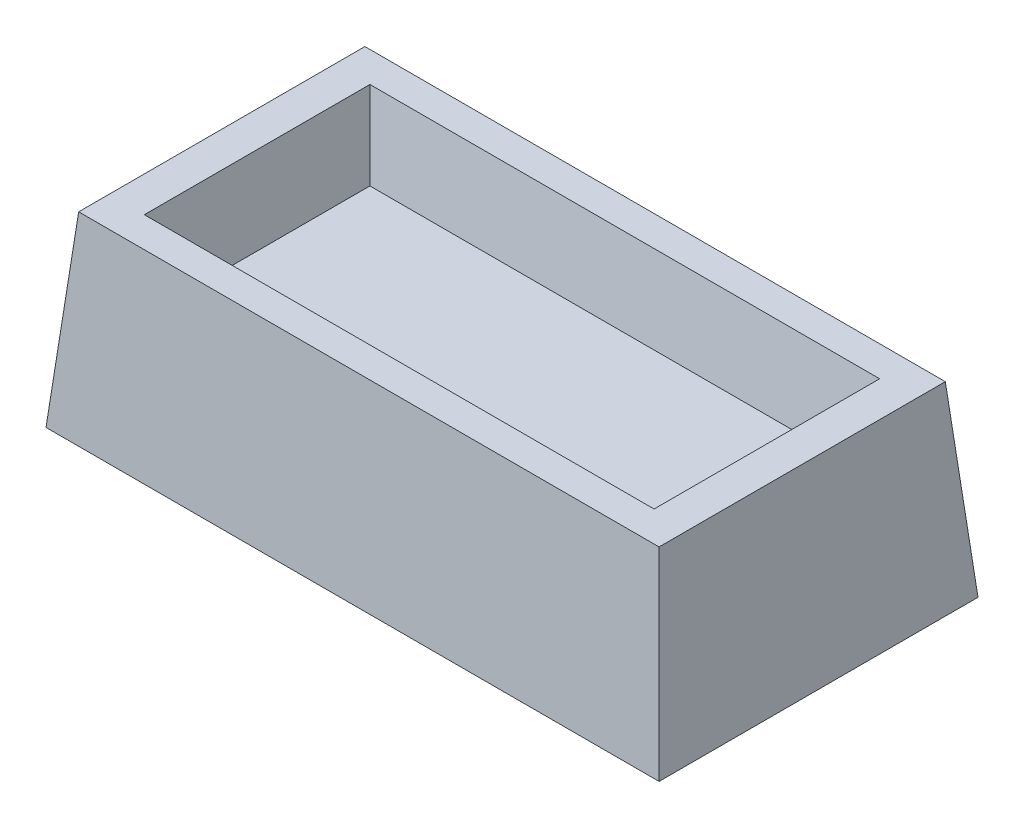
from build123d import *

# Parameters (mm, degrees)
SKETCH1_W           = 164.136897748
SKETCH1_H           = 85.377660522
BOSS_EXTRUDE1_DEPTH = 50
BOSS_EXTRUDE1_TAPER = 5
SKETCH2_W           = 136.467789358
SKETCH2_H           = 60.390918278
CUT_EXTRUDE1_DEPTH  = 20
CUT_EXTRUDE1_TAPER  = 10
SHELL1_T            = -3


with BuildPart() as part:
    # Sketch1 → Boss-Extrude1 (new body)
    with BuildSketch(Plane(origin=(0, 0, 0), x_dir=(1, 0, 0), z_dir=(0, 1, 0))):
        Rectangle(SKETCH1_W, SKETCH1_H)
    extrude(amount=BOSS_EXTRUDE1_DEPTH, taper=BOSS_EXTRUDE1_TAPER)

    # Sketch2 → Cut-Extrude1 (cut)
    with BuildSketch(Plane(origin=(0, 50, 0), x_dir=(1, 0, 0), z_dir=(0, 1, 0))):
        Rectangle(SKETCH2_W, SKETCH2_H)
    extrude(amount=-CUT_EXTRUDE1_DEPTH, taper=CUT_EXTRUDE1_TAPER, mode=Mode.SUBTRACT)

    # Shell1
    shell1_openings = [part.faces().sort_by_distance(p)[0] for p in [
        (0, 0, 0),
    ]]
    offset(amount=SHELL1_T, openings=shell1_openings, kind=Kind.INTERSECTION)


solid = part.part
